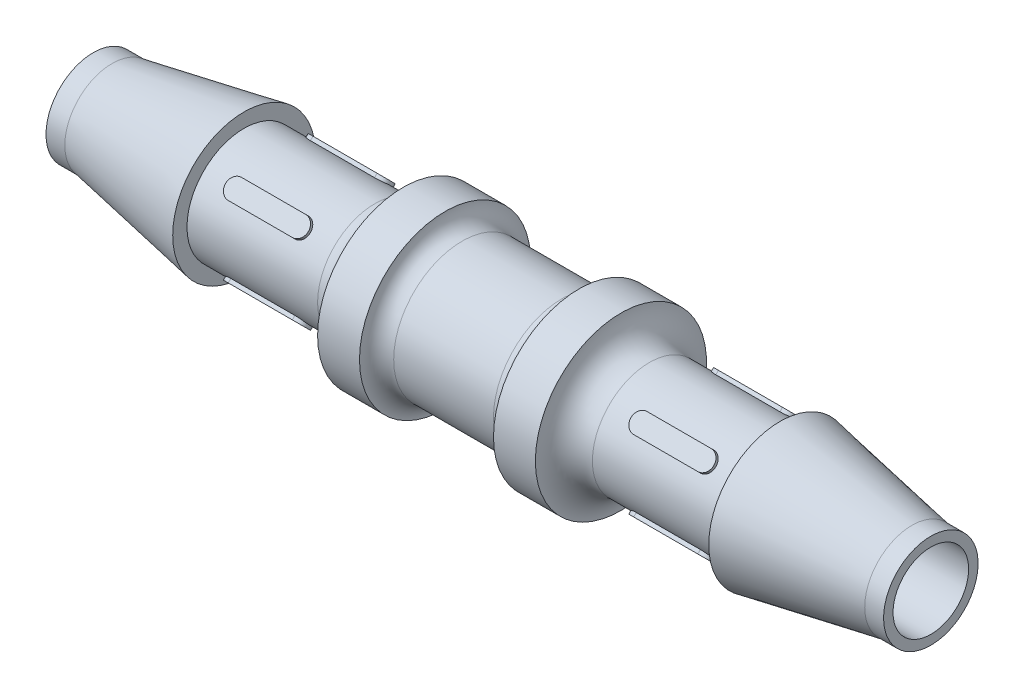
from build123d import *

# Parameters (mm, degrees)
EXTRUDE1_DEPTH     = 3.36042
CIRPATTERN1_COUNT  = 2
CIRPATTERN1_ANGLE  = 90
SKETCH4_R          = 2.1209
CUT_EXTRUDE1_DEPTH = 24.4950001


with BuildPart() as part:
    # Sketch1 → Revolve1 (revolve)
    with BuildSketch(Plane.XY):
        Polygon((23.495, 2.1209), (23.495, 2.651125), (22.437725, 2.651125), (15.0368, 4.0005), (15.0368, 3.2004), (6.1087, 3.2004), (6.1087, 4.8006), (3.7592, 4.8006), (3.7592, 3.84048), (0, 3.84048), (0, 2.1209), align=None)
    revolve(axis=Axis((0, 0, 0), (1, 0, 0)))

    # Sketch2 → Revolve2 (revolve)
    with BuildSketch(Plane.XY):
        with BuildLine():
            Line((7.7089, 3.2004), (6.1087, 3.2004))
            Line((6.1087, 3.2004), (6.1087, 4.8006))
            ThreePointArc((6.1087, 4.8006), (6.577387729, 3.669087729), (7.7089, 3.2004))
        make_face()
        with BuildLine():
            Line((3.7592, 4.8006), (3.7592, 3.84048))
            Line((3.7592, 3.84048), (2.79908, 3.84048))
            ThreePointArc((2.79908, 3.84048), (3.477987363, 4.121692637), (3.7592, 4.8006))
        make_face()
    revolve(axis=Axis((0, 0, 0), (1, 0, 0)))

    # Sketch3 → Extrude1 (add, symmetric)
    with BuildSketch(Plane(origin=(0, 0, 0), x_dir=(-1, 0, 0), z_dir=(0, 0.707106781, 0.707106781))):
        with BuildLine():
            Line((-9.5754825, 0.5286375), (-13.1702175, 0.5286375))
            ThreePointArc((-13.1702175, 0.5286375), (-13.698855, 0), (-13.1702175, -0.5286375))
            Line((-13.1702175, -0.5286375), (-9.5754825, -0.5286375))
            ThreePointArc((-9.5754825, -0.5286375), (-9.046845, 0), (-9.5754825, 0.5286375))
        make_face()
    extrude1 = extrude(amount=EXTRUDE1_DEPTH, both=True)

    # CirPattern1: Extrude1 ×2 about axis
    cirpattern1_axis = Axis((0, 0, 0), (1, 0, 0))
    for i in range(1, CIRPATTERN1_COUNT):
        add(extrude1.rotate(cirpattern1_axis, i * CIRPATTERN1_ANGLE / (CIRPATTERN1_COUNT - 1)))

    # Sketch4 → Cut-Extrude1 (cut, through all)
    with BuildSketch(Plane(origin=(23.495, 0, 0), x_dir=(0, 0, -1), z_dir=(1, 0, 0))):
        Circle(SKETCH4_R)
    extrude(amount=-CUT_EXTRUDE1_DEPTH, mode=Mode.SUBTRACT)

    # Mirror1: part across plane


with BuildPart() as part_1:
    add(part.part)
    add(part.part.mirror(Plane(origin=(0, 0, 0), x_dir=(0, 0, 1), z_dir=(1, 0, 0))))


solid = part_1.part
